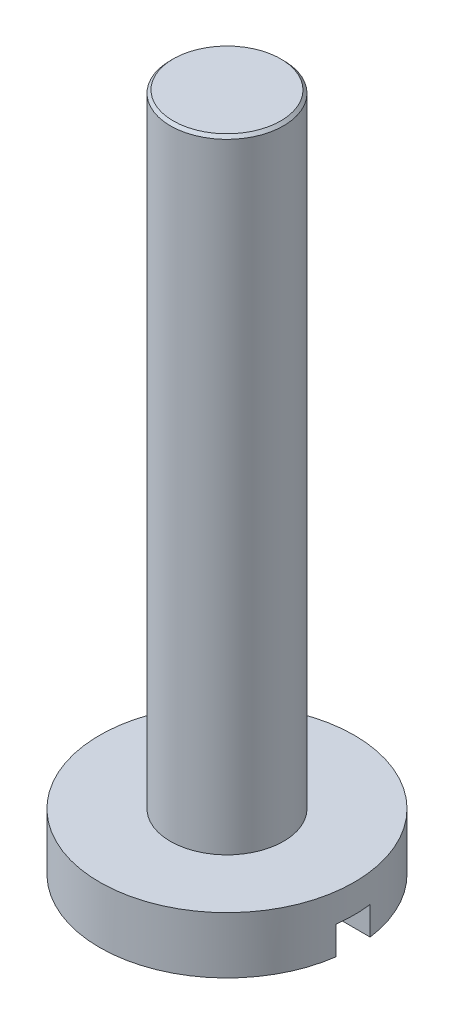
from build123d import *

# Parameters (mm, degrees)
SKETCH1_R           = 1
BOSS_EXTRUDE1_DEPTH = 11
SKETCH2_R           = 2.25
BOSS_EXTRUDE2_DEPTH = 1
SKETCH3_W           = 8.196351728
SKETCH3_H           = 0.6
CUT_EXTRUDE1_DEPTH  = 0.5
CHAMFER1_SIZE       = 0.05


with BuildPart() as part:
    # Sketch1 → Boss-Extrude1 (new body)
    with BuildSketch(Plane(origin=(0, 0, 0), x_dir=(1, 0, 0), z_dir=(0, 1, 0))):
        Circle(SKETCH1_R)
    extrude(amount=BOSS_EXTRUDE1_DEPTH)

    # Chamfer1
    chamfer1_edges = [part.edges().sort_by_distance(p)[0] for p in [
        (-1, 11, 0),
    ]]
    chamfer(chamfer1_edges, length=CHAMFER1_SIZE)


with BuildPart() as body_2:
    # Sketch2 → Boss-Extrude2 (new body)
    with BuildSketch(Plane.XZ):
        Circle(SKETCH2_R)
    extrude(amount=BOSS_EXTRUDE2_DEPTH)

    # Sketch3 → Cut-Extrude1 (cut)
    with BuildSketch(Plane.XZ.offset(1)):
        Rectangle(SKETCH3_W, SKETCH3_H)
    extrude(amount=-CUT_EXTRUDE1_DEPTH, mode=Mode.SUBTRACT)


solid = Compound([part.part, body_2.part])
